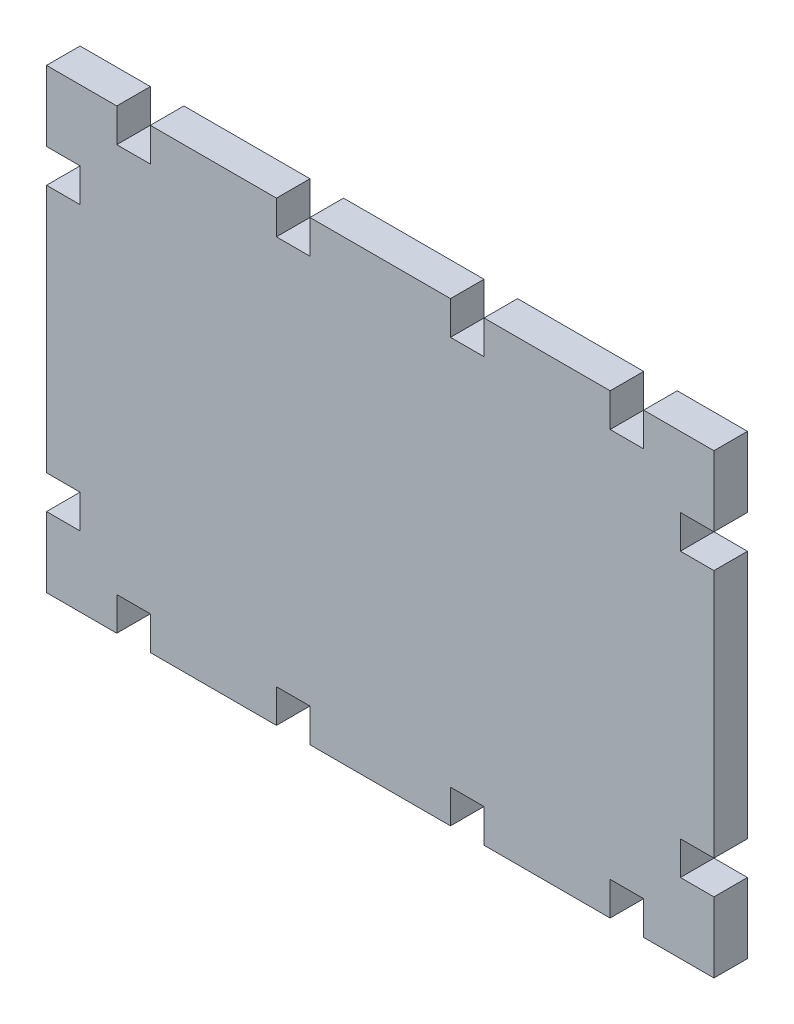
from build123d import *

# Parameters (mm, degrees)
BOSS_EXTRUDE1_DEPTH = 4.7752


with BuildPart() as part:
    # Sketch3 → Boss-Extrude1 (new body)
    with BuildSketch(Plane.XY):
        Polygon((10, 0), (10, 4.7752), (14.7752, 4.7752), (14.7752, 0), (32.7248, 0), (32.7248, 4.7752), (37.5, 4.7752), (37.5, 0), (47.5, 0), (57.5, 0), (57.5, 4.7752), (62.2752, 4.7752), (62.2752, 0), (80.2248, 0), (80.2248, 4.7752), (85, 4.7752), (85, 0), (95, 0), (95, 10), (90.2248, 10), (90.2248, 14.7752), (95, 14.7752), (95, 32.5), (95, 50.2248), (90.2248, 50.2248), (90.2248, 55), (95, 55), (95, 65), (85, 65), (85, 60.2248), (80.2248, 60.2248), (80.2248, 65), (62.2752, 65), (62.2752, 60.2248), (57.5, 60.2248), (57.5, 65), (37.5, 65), (37.5, 60.2248), (32.7248, 60.2248), (32.7248, 65), (14.7752, 65), (14.7752, 60.2248), (10, 60.2248), (10, 65), (0, 65), (0, 55), (4.7752, 55), (4.7752, 50.2248), (0, 50.2248), (0, 14.7752), (4.7752, 14.7752), (4.7752, 10), (0, 10), (0, 0), align=None)
    extrude(amount=-BOSS_EXTRUDE1_DEPTH)


solid = part.part
